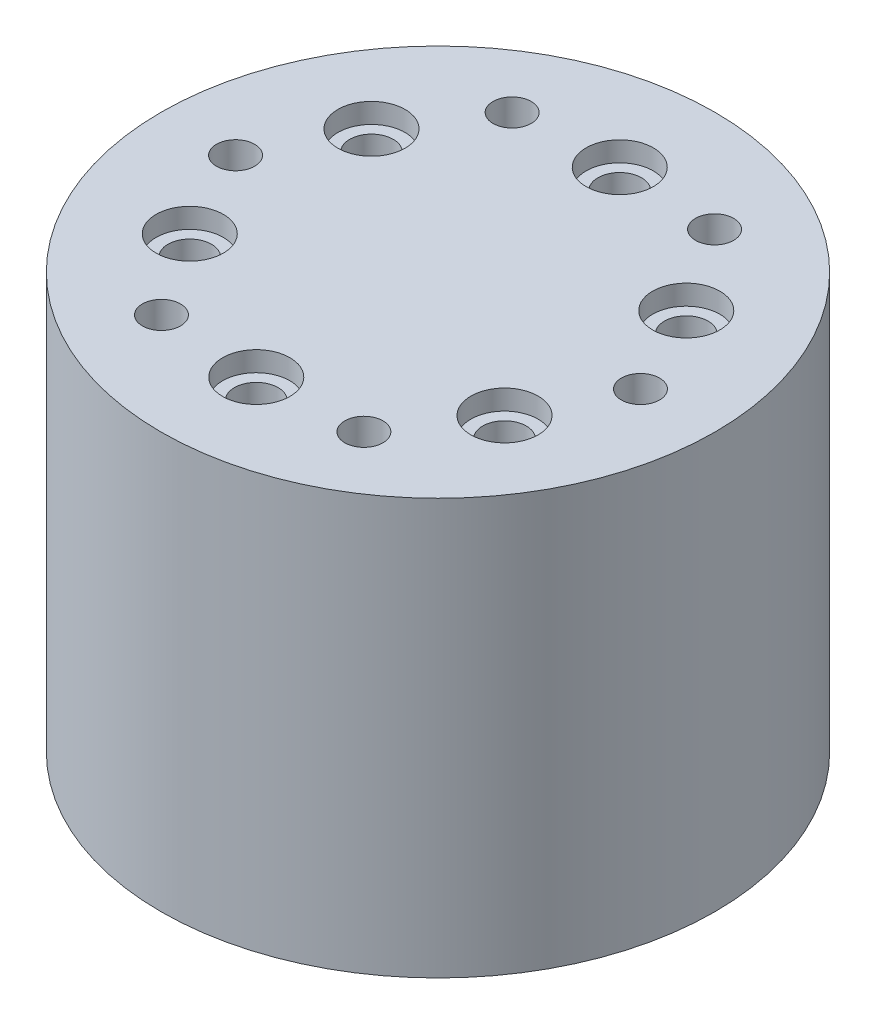
from build123d import *

# Parameters (mm, degrees)
SKETCH1_R                        = 76.2
BOSS_EXTRUDE1_DEPTH              = 114.3
CBORE_FOR_M10_SBHCS1_D           = 12
CBORE_FOR_M10_SBHCS1_CBORE_D     = 18.5
CBORE_FOR_M10_SBHCS1_CBORE_DEPTH = 5.5
CIRPATTERN1_COUNT                = 6


with BuildPart() as part:
    # Sketch1 → Boss-Extrude1 (new body)
    with BuildSketch(Plane(origin=(0, 0, 0), x_dir=(1, 0, 0), z_dir=(0, 1, 0))):
        Circle(SKETCH1_R)
    extrude(amount=BOSS_EXTRUDE1_DEPTH)

    # CBORE for M10 SBHCS1 (through all)
    with Locations(Plane(origin=(0, 114.3, 0), x_dir=(1, 0, 0), z_dir=(0, 1, 0))):
        with Locations((0, 50), (43.301270189, 25), (43.301270189, -25), (0, -50), (-43.301270189, -25), (-43.301270189, 25)):
            CounterBoreHole(CBORE_FOR_M10_SBHCS1_D / 2, CBORE_FOR_M10_SBHCS1_CBORE_D / 2, CBORE_FOR_M10_SBHCS1_CBORE_DEPTH)

    # Sketch47 → Tap Drill for M10 Helicoil1 (revolve, cut)
    with BuildSketch(Plane(origin=(55.7, 114.3, 0), x_dir=(0, 0, 1), z_dir=(1, 0, 0))):
        Polygon((0, 0), (0, 28.15451825), (5.25, 25), (5.25, 0), align=None)
    tap_drill_for_m10_helicoil1 = revolve(axis=Axis((55.7, 120.65, 0), (0, -1, 0)), mode=Mode.SUBTRACT)

    # CirPattern1: Tap Drill for M10 Helicoil1 ×6 about axis
    cirpattern1_axis = Axis((0, 0, 0), (0, 1, 0))
    for i in range(1, CIRPATTERN1_COUNT):
        add(tap_drill_for_m10_helicoil1.rotate(cirpattern1_axis, i * 360 / CIRPATTERN1_COUNT), mode=Mode.SUBTRACT)


solid = part.part
